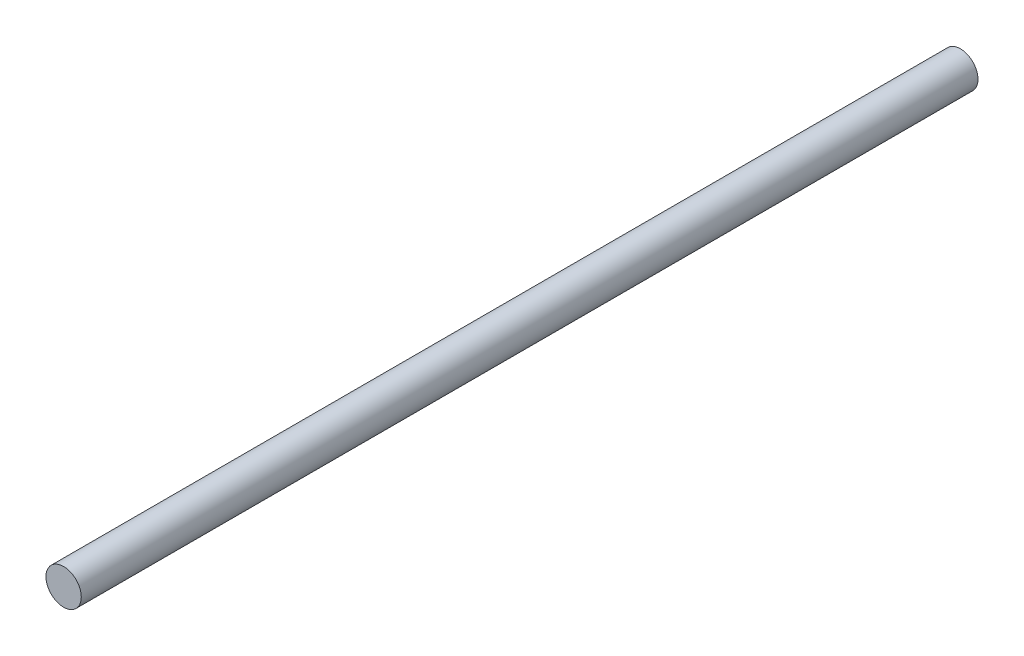
from build123d import *

# Parameters (mm, degrees)
SKETCH1_R           = 2.999994
BOSS_EXTRUDE1_DEPTH = 152.4


with BuildPart() as part:
    # Sketch1 → Boss-Extrude1 (new body)
    with BuildSketch(Plane.XY):
        Circle(SKETCH1_R)
    extrude(amount=BOSS_EXTRUDE1_DEPTH)


solid = part.part
